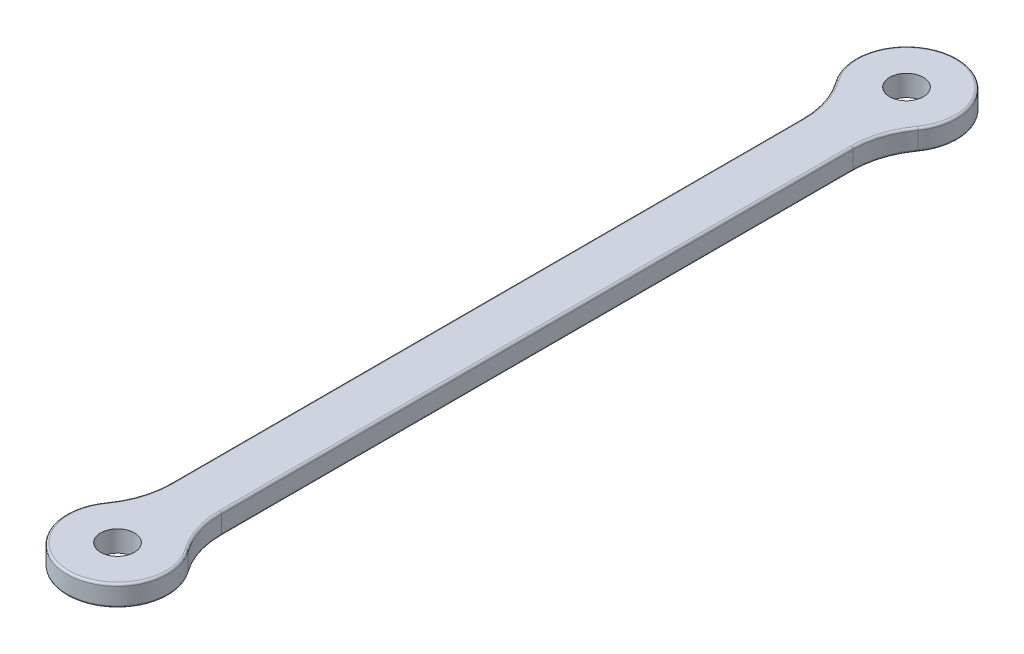
from build123d import *

# Parameters (mm, degrees)
SKETCH1_R           = 2
BOSS_EXTRUDE1_DEPTH = 2.5
FILLET1_R           = 10
FILLET2_R           = 0.25


with BuildPart() as part:
    # Sketch1 → Boss-Extrude1 (new body)
    with BuildSketch(Plane(origin=(0, 0, 0), x_dir=(1, 0, 0), z_dir=(0, 1, 0))):
        with BuildLine():
            ThreePointArc((-3, -41.553847577), (0, -52.75), (3, -41.553847577))
            Line((3, -41.553847577), (3, 41.553847577))
            ThreePointArc((3, 41.553847577), (0, 52.75), (-3, 41.553847577))
            Line((-3, 41.553847577), (-3, -41.553847577))
        make_face()
        with Locations((0, -46.75)):
            Circle(SKETCH1_R, mode=Mode.SUBTRACT)
        with Locations((0, 46.75)):
            Circle(SKETCH1_R, mode=Mode.SUBTRACT)
    extrude(amount=BOSS_EXTRUDE1_DEPTH)

    # Fillet1
    fillet1_edges = [part.edges().sort_by_distance(p)[0] for p in [
        (-3, 1.25, 41.553847577),
        (-3, 1.25, -41.553847577),
        (3, 1.25, -41.553847577),
        (3, 1.25, 41.553847577),
    ]]
    fillet(fillet1_edges, radius=FILLET1_R)

    # Fillet2
    fillet2_edges = [part.edges().sort_by_distance(p)[0] for p in [
        (0, 0, 52.75),
        (0, 2.5, 52.75),
        (-3, 0, 0),
        (-3, 2.5, 0),
        (0, 0, -52.75),
        (0, 2.5, -52.75),
        (3, 0, 0),
        (3, 2.5, 0),
        (-3.480283618, 0, 40.484483125),
        (-3.480283618, 2.5, 40.484483125),
        (-3.480283618, 0, -40.484483125),
        (-3.480283618, 2.5, -40.484483125),
        (3.480283618, 0, -40.484483125),
        (3.480283618, 2.5, -40.484483125),
        (3.480283618, 0, 40.484483125),
        (3.480283618, 2.5, 40.484483125),
    ]]
    fillet(fillet2_edges, radius=FILLET2_R)


solid = part.part
